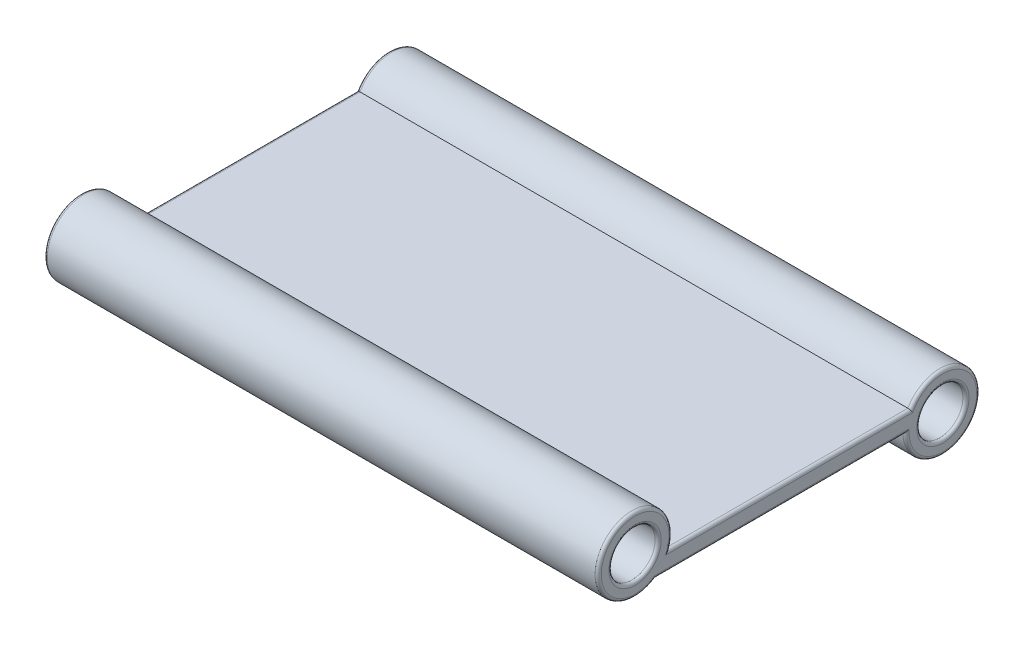
from build123d import *

# Parameters (mm, degrees)
SKETCH1_W           = 18
SKETCH1_H           = 10
BOSS_EXTRUDE1_DEPTH = 0.6
SKETCH2_R           = 1.2
BOSS_EXTRUDE2_DEPTH = 18
SKETCH3_R           = 0.75
CUT_EXTRUDE1_DEPTH  = 18
SKETCH8_R           = 0.6
CUT_EXTRUDE4_DEPTH  = 6
FILLET5_R           = 0.1


with BuildPart() as part:
    # Sketch1 → Boss-Extrude1 (new body)
    with BuildSketch(Plane(origin=(0, 0, 0), x_dir=(1, 0, 0), z_dir=(0, 1, 0))):
        with Locations((0, 1.25)):
            Rectangle(SKETCH1_W, SKETCH1_H)
    extrude(amount=BOSS_EXTRUDE1_DEPTH)

    # Sketch2 → Boss-Extrude2 (add)
    with BuildSketch(Plane(origin=(9, 0, 0), x_dir=(0, 0, -1), z_dir=(1, 0, 0))):
        with Locations((-3.75, 1)):
            Circle(SKETCH2_R)
        with Locations((6.25, 0)):
            Circle(SKETCH2_R)
    extrude(amount=-BOSS_EXTRUDE2_DEPTH)

    # Sketch3 → Cut-Extrude1 (cut)
    with BuildSketch(Plane(origin=(9, 0, 0), x_dir=(0, 0, -1), z_dir=(1, 0, 0))):
        with Locations((-3.75, 1)):
            Circle(SKETCH3_R)
        with Locations((6.25, 0)):
            Circle(SKETCH3_R)
    extrude(amount=-CUT_EXTRUDE1_DEPTH, mode=Mode.SUBTRACT)

    # Sketch8 → Cut-Extrude4 (cut, symmetric)
    with BuildSketch(Plane(origin=(0, 0, 0), x_dir=(0, 0, -1), z_dir=(1, 0, 0))):
        with Locations((-3.85, 1.2)):
            Circle(SKETCH8_R)
    extrude(amount=CUT_EXTRUDE4_DEPTH, both=True, mode=Mode.SUBTRACT)

    # Fillet5
    fillet5_edges = [part.edges().sort_by_distance(p)[0] for p in [
        (9, 0, -0.981662479),
        (9, 0.6, -1.296070183),
        (-9, 1.738083152, 4.696167671),
        (9, 1.738083152, 4.696167671),
        (-9, 0, -0.981662479),
        (-9, 0.6, -1.296070183),
        (-9, -0.310582854, -7.409110992),
        (9, -0.310582854, -7.409110992),
        (-9, 1, 4.5),
        (9, 1, 4.5),
        (-9, 0, -5.5),
        (9, 0, -5.5),
    ]]
    fillet(fillet5_edges, radius=FILLET5_R)


solid = part.part
